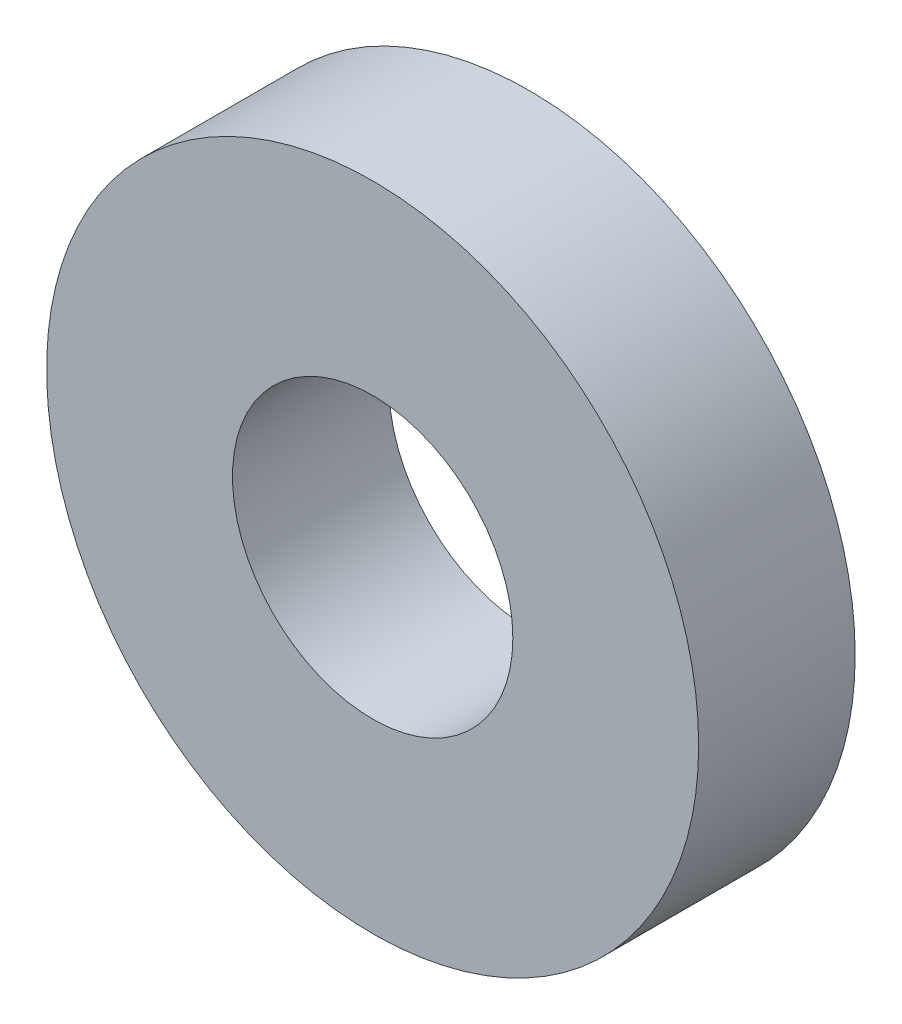
from build123d import *

# Parameters (mm, degrees)
SKETCH1_R           = 5
SKETCH1_R_2         = 2.15
BOSS_EXTRUDE1_DEPTH = 2.4


with BuildPart() as part:
    # Sketch1 → Boss-Extrude1 (new body)
    with BuildSketch(Plane.XY):
        Circle(SKETCH1_R)
        Circle(SKETCH1_R_2, mode=Mode.SUBTRACT)
    extrude(amount=BOSS_EXTRUDE1_DEPTH)


solid = part.part
